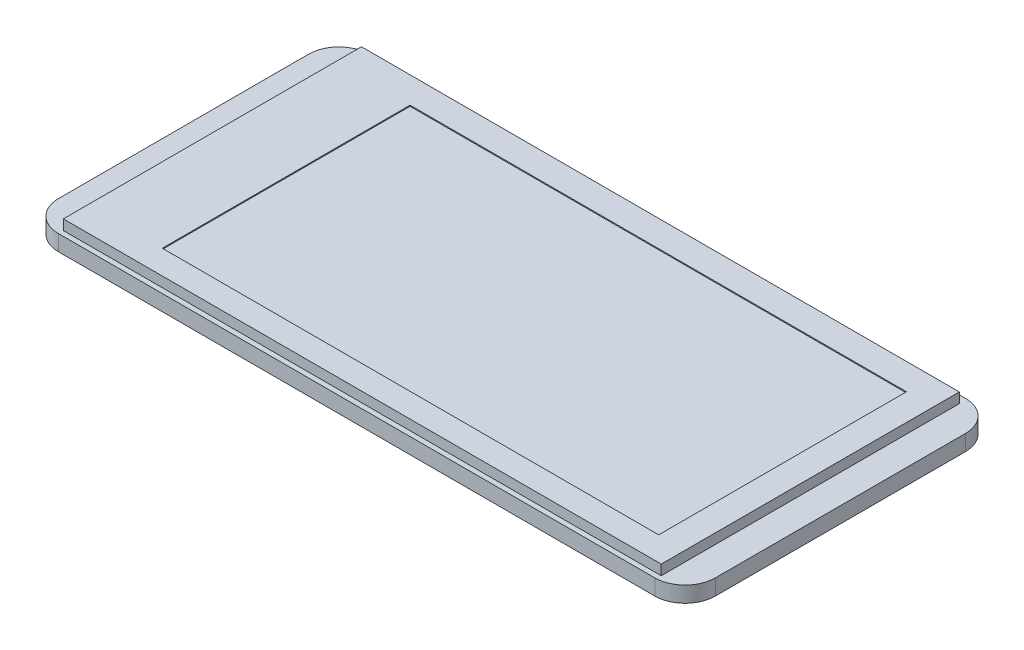
from build123d import *

# Parameters (mm, degrees)
EXTRUDE_1_DEPTH     = 1.56
SKETCH_3_W          = 59.16
SKETCH_3_H          = 29.5
EXTRUDE_2_DEPTH     = 1
SKETCH_8_W          = 51
SKETCH_8_H          = 5
EXTRUDE_6_DEPTH     = 3.68
SKETCH_9_W          = 49.12
SKETCH_9_H          = 24.52
CUT_EXTRUDE_1_DEPTH = 0.1


with BuildPart() as part:
    # 草图1 → 凸台-拉伸1 (new body)
    with BuildSketch(Plane(origin=(0, 0, 0), x_dir=(1, 0, 0), z_dir=(0, 1, 0))):
        with BuildLine():
            Line((-29.5, 15.375), (29.5, 15.375))
            ThreePointArc((29.5, 15.375), (31.621320344, 14.496320344), (32.5, 12.375))
            Line((32.5, 12.375), (32.5, -12.375))
            ThreePointArc((32.5, -12.375), (31.621320344, -14.496320344), (29.5, -15.375))
            Line((29.5, -15.375), (-29.5, -15.375))
            ThreePointArc((-29.5, -15.375), (-31.621320344, -14.496320344), (-32.5, -12.375))
            Line((-32.5, -12.375), (-32.5, 12.375))
            ThreePointArc((-32.5, 12.375), (-31.621320344, 14.496320344), (-29.5, 15.375))
        make_face()
    extrude(amount=EXTRUDE_1_DEPTH)

    # 草图3 → 凸台-拉伸2 (add)
    with BuildSketch(Plane(origin=(0, 1.56, 0), x_dir=(1, 0, 0), z_dir=(0, 1, 0))):
        with Locations((0.06, -0.125)):
            Rectangle(SKETCH_3_W, SKETCH_3_H)
    extrude(amount=EXTRUDE_2_DEPTH)

    # 草图8 → 凸台-拉伸6 (add)
    with BuildSketch(Plane.XZ):
        with Locations((-0.2, -11.235)):
            Rectangle(SKETCH_8_W, SKETCH_8_H)
    extrude(amount=EXTRUDE_6_DEPTH)

    # 草图9 → 切除-拉伸1 (cut)
    with BuildSketch(Plane(origin=(0, 2.56, 0), x_dir=(1, 0, 0), z_dir=(0, 1, 0))):
        with Locations((2.45, -0.235)):
            Rectangle(SKETCH_9_W, SKETCH_9_H)
    extrude(amount=-CUT_EXTRUDE_1_DEPTH, mode=Mode.SUBTRACT)


solid = part.part
